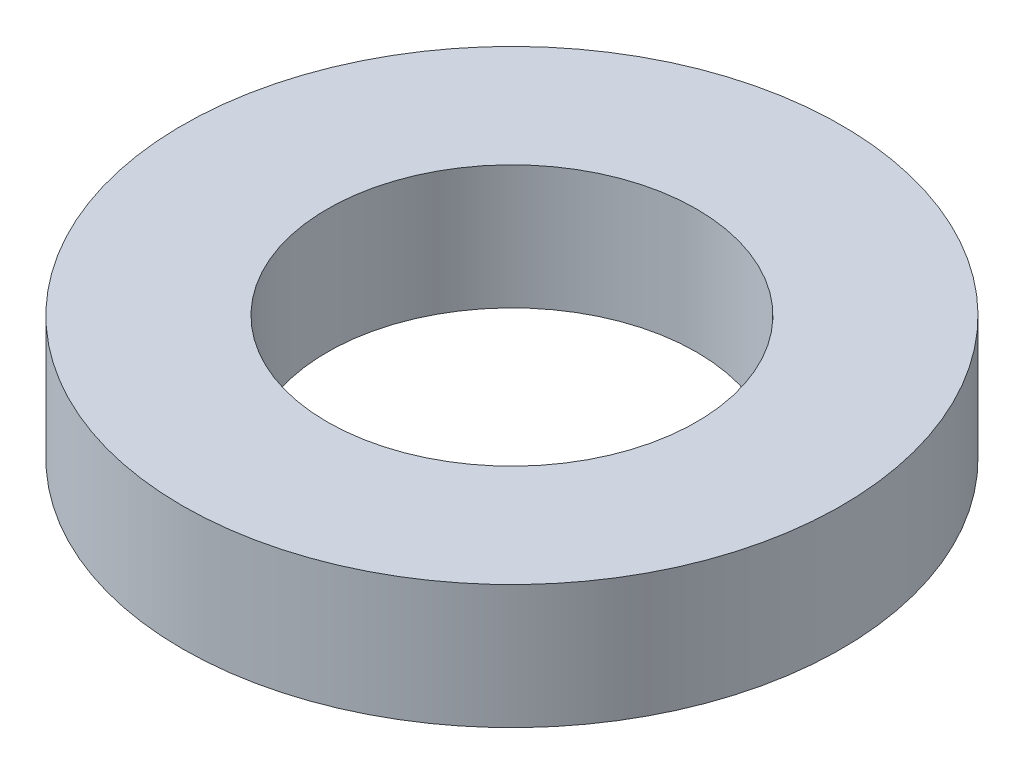
from build123d import *

# Parameters (mm, degrees)
SKETCH1_R          = 3.175
EXTRUDE1_DEPTH     = 1.1938
SKETCH2_R          = 1.778
CUT_EXTRUDE1_DEPTH = 1.1938


with BuildPart() as part:
    # Sketch1 → Extrude1 (new body)
    with BuildSketch(Plane(origin=(0, 0, 0), x_dir=(1, 0, 0), z_dir=(0, 1, 0))):
        Circle(SKETCH1_R)
    extrude(amount=EXTRUDE1_DEPTH)

    # Sketch2 → Cut-Extrude1 (cut)
    with BuildSketch(Plane(origin=(0, 1.1938, 0), x_dir=(-1, 0, 0), z_dir=(0, 1, 0))):
        Circle(SKETCH2_R)
    extrude(amount=-CUT_EXTRUDE1_DEPTH, mode=Mode.SUBTRACT)


solid = part.part
